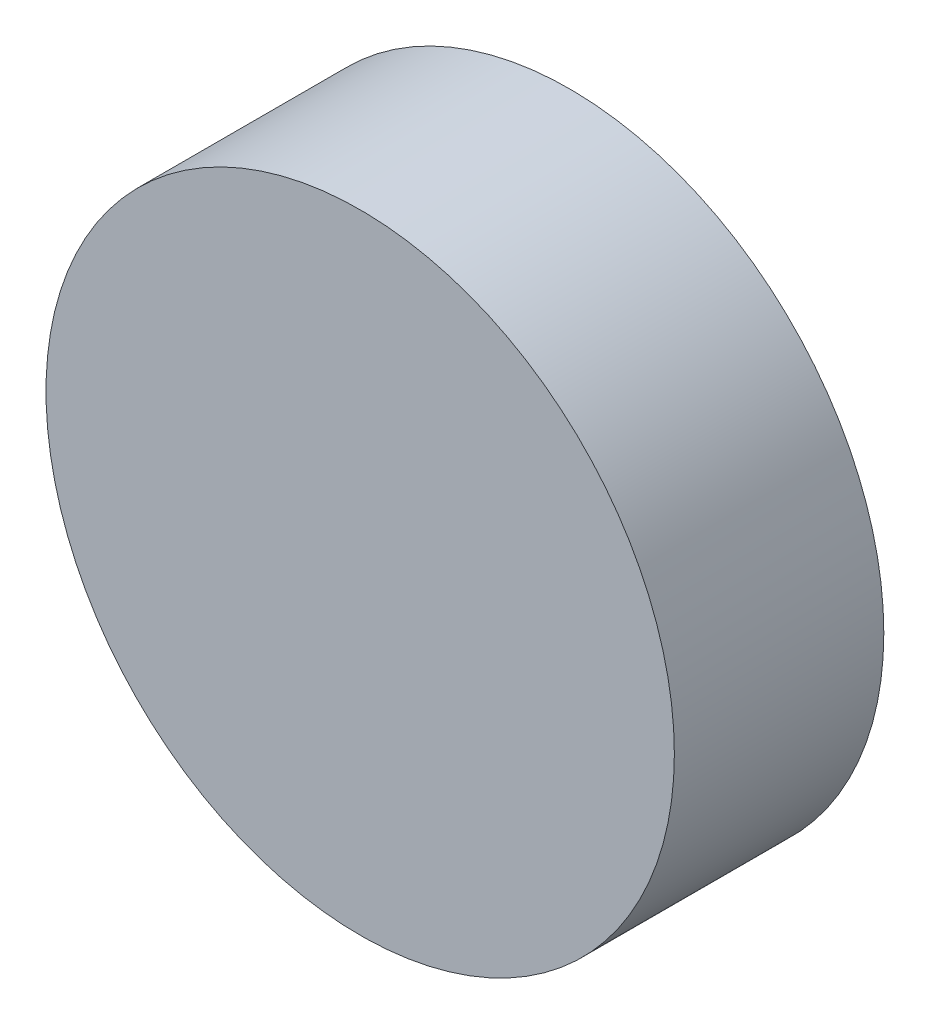
from build123d import *

# Parameters (mm, degrees)
SKETCH1_R           = 2.38125
BOSS_EXTRUDE1_DEPTH = 1.5875


with BuildPart() as part:
    # Sketch1 → Boss-Extrude1 (new body)
    with BuildSketch(Plane.XY):
        Circle(SKETCH1_R)
    extrude(amount=BOSS_EXTRUDE1_DEPTH)


solid = part.part
